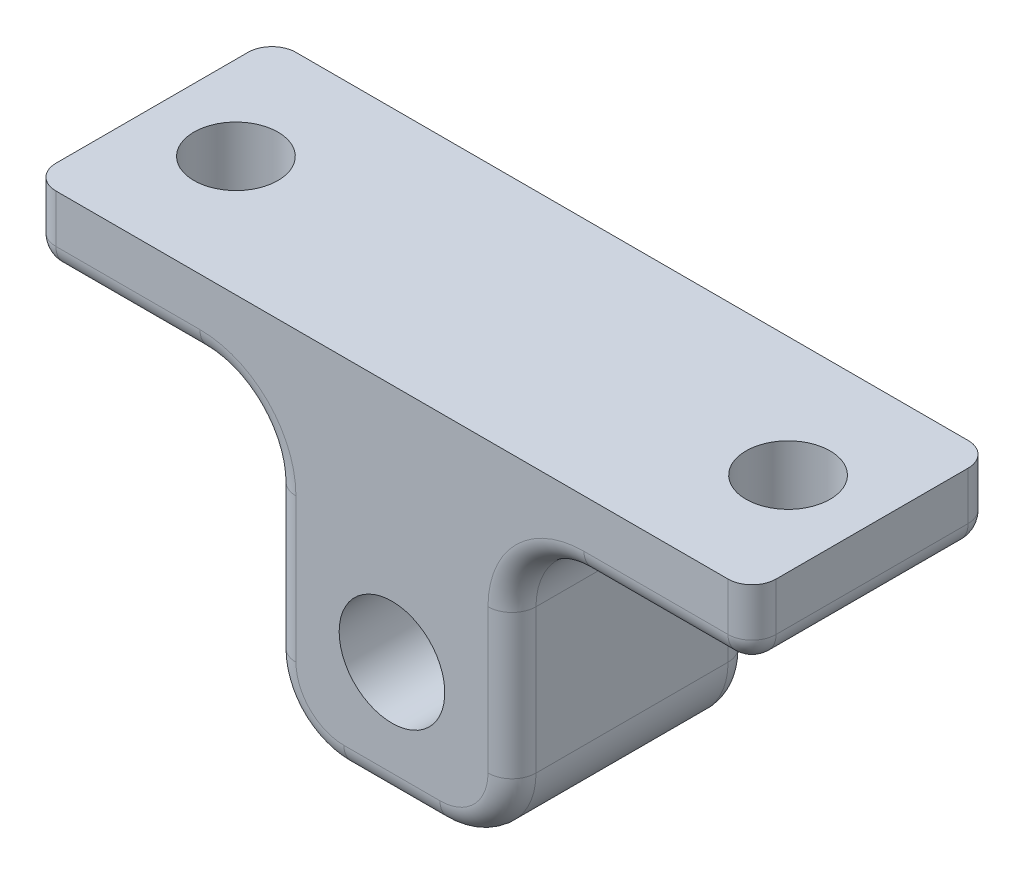
from build123d import *

# Parameters (mm, degrees)
SKETCH_1_W          = 10
SKETCH_1_H          = 3
EXTRUDE_1_DEPTH     = 10
SKETCH_2_R          = 2.2
CUT_EXTRUDE_1_DEPTH = 11
SKETCH_3_R          = 1.75
CUT_EXTRUDE_2_DEPTH = 4
FILLET_1_R          = 3
FILLET_2_R          = 1


with BuildPart() as part:
    # ｽｹｯﾁ1 → ﾎﾞｽ - 押し出し1 (new body)
    with BuildSketch(Plane.XY):
        Polygon((5, 10), (0, 10), (0, -5), (5, -5), (5, 7), align=None)
        with Locations((10, 8.5)):
            Rectangle(SKETCH_1_W, SKETCH_1_H)
        Polygon((0, -5), (0, 10), (-5, 10), (-5, 7), (-5, -5), align=None)
        with Locations((-10, 8.5)):
            Rectangle(SKETCH_1_W, SKETCH_1_H)
    extrude(amount=EXTRUDE_1_DEPTH)

    # ｽｹｯﾁ2 → ｶｯﾄ - 押し出し1 (cut, through all)
    with BuildSketch(Plane(origin=(0, 0, 0), x_dir=(-1, 0, 0), z_dir=(0, 0, -1))):
        Circle(SKETCH_2_R)
    extrude(amount=-CUT_EXTRUDE_1_DEPTH, mode=Mode.SUBTRACT)

    # ｽｹｯﾁ3 → ｶｯﾄ - 押し出し2 (cut, through all)
    with BuildSketch(Plane.XZ.offset(-7)):
        with Locations((-11.5, 5)):
            Circle(SKETCH_3_R)
        with Locations((11.5, 5)):
            Circle(SKETCH_3_R)
    extrude(amount=-CUT_EXTRUDE_2_DEPTH, mode=Mode.SUBTRACT)

    # ﾌｨﾚｯﾄ1
    fillet_1_edges = [part.edges().sort_by_distance(p)[0] for p in [
        (5, -5, 5),
        (-5, -5, 5),
        (-5, 7, 5),
        (5, 7, 5),
    ]]
    fillet(fillet_1_edges, radius=FILLET_1_R)

    # ﾌｨﾚｯﾄ2
    fillet_2_edges = [part.edges().sort_by_distance(p)[0] for p in [
        (-15, 8.5, 0),
        (15, 8.5, 0),
        (15, 8.5, 10),
        (-15, 7, 5),
        (15, 7, 5),
        (-15, 8.5, 10),
        (-5, 1, 0),
        (-5, 1, 10),
        (-11.5, 7, 0),
        (-11.5, 7, 10),
        (11.5, 7, 0),
        (11.5, 7, 10),
        (5, 1, 0),
        (5, 1, 10),
        (0, -5, 0),
        (0, -5, 10),
        (4.121320344, -4.121320344, 0),
        (-4.121320344, -4.121320344, 0),
        (4.121320344, -4.121320344, 10),
        (-4.121320344, -4.121320344, 10),
        (-5.878679656, 6.121320344, 0),
        (-5.878679656, 6.121320344, 10),
        (5.878679656, 6.121320344, 0),
        (5.878679656, 6.121320344, 10),
    ]]
    fillet(fillet_2_edges, radius=FILLET_2_R)


solid = part.part
